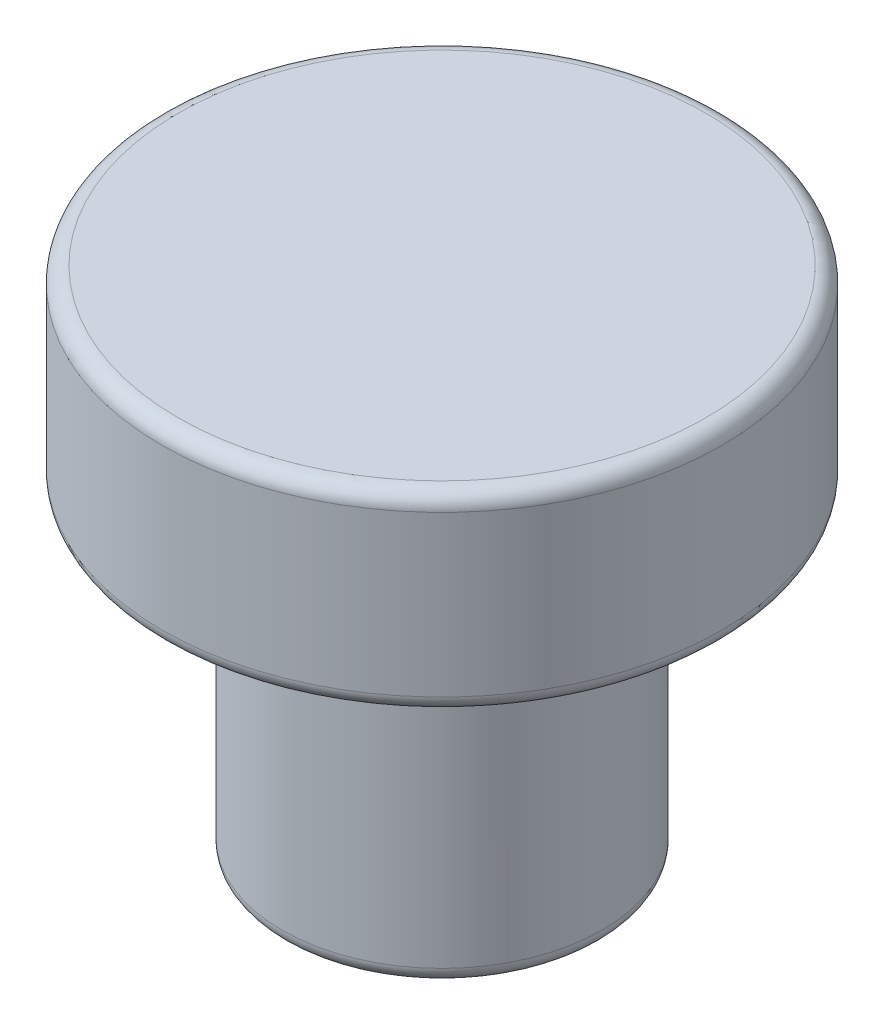
from build123d import *

# Parameters (mm, degrees)
SKETCH1_R           = 17.5
BOSS_EXTRUDE1_DEPTH = 12
SKETCH2_R           = 10
BOSS_EXTRUDE2_DEPTH = 20
FILLET1_R           = 1


with BuildPart() as part:
    # Sketch1 → Boss-Extrude1 (new body)
    with BuildSketch(Plane(origin=(0, 0, 0), x_dir=(1, 0, 0), z_dir=(0, 1, 0))):
        Circle(SKETCH1_R)
    extrude(amount=BOSS_EXTRUDE1_DEPTH)

    # Sketch2 → Boss-Extrude2 (add)
    with BuildSketch(Plane.XZ):
        Circle(SKETCH2_R)
    extrude(amount=BOSS_EXTRUDE2_DEPTH)

    # Fillet1
    fillet1_edges = [part.edges().sort_by_distance(p)[0] for p in [
        (-17.5, 0, 0),
        (-17.5, 12, 0),
        (-10, 0, 0),
        (-10, -20, 0),
    ]]
    fillet(fillet1_edges, radius=FILLET1_R)


solid = part.part
